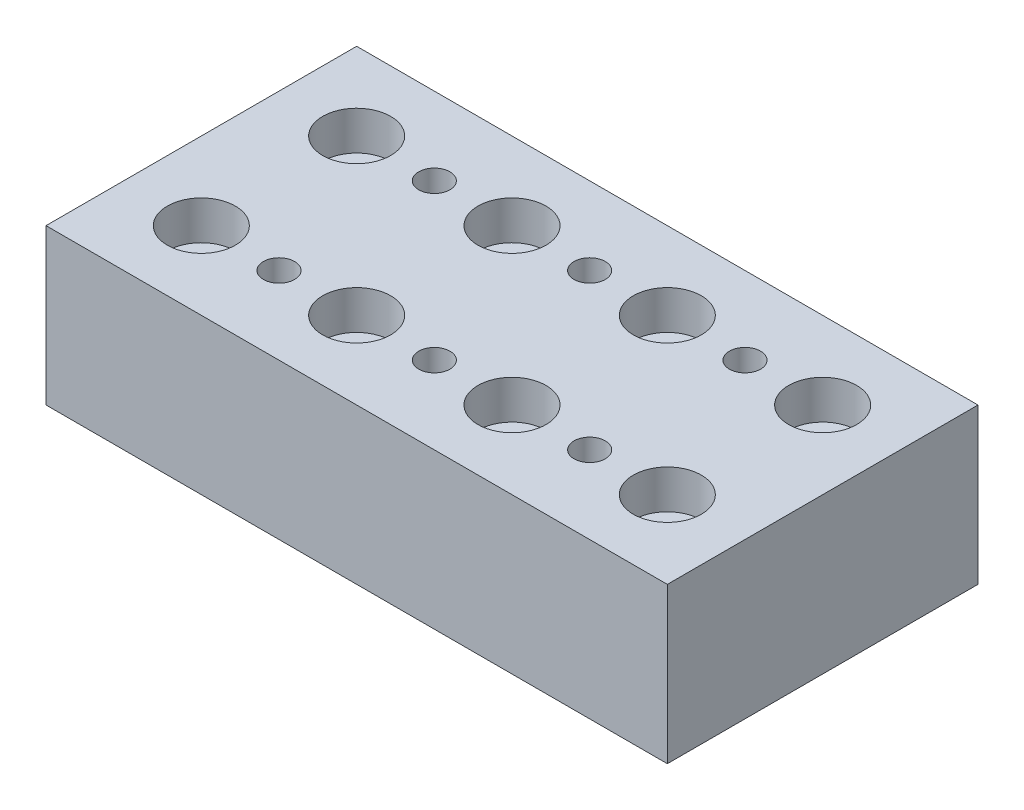
from build123d import *

# Parameters (mm, degrees)
SKETCH1_W                                        = 101.6
SKETCH1_H                                        = 50.8
BOSS_EXTRUDE1_DEPTH                              = 25.4
CBORE_FOR_1_4_SOCKET_HEAD_CAP_SCREW1_D           = 6.7564
CBORE_FOR_1_4_SOCKET_HEAD_CAP_SCREW1_CBORE_D     = 11.1125
CBORE_FOR_1_4_SOCKET_HEAD_CAP_SCREW1_CBORE_DEPTH = 6.35
LPATTERN1_COUNT                                  = 2
LPATTERN1_PITCH                                  = 25.4
LPATTERN1_COUNT_DIR2                             = 4
LPATTERN1_PITCH_DIR2                             = 25.4
F_1_4_20_TAPPED_HOLE1_D                          = 5.1054
LPATTERN2_COUNT                                  = 2
LPATTERN2_PITCH                                  = 25.4
LPATTERN2_COUNT_DIR2                             = 3
LPATTERN2_PITCH_DIR2                             = 25.4


with BuildPart() as part:
    # Sketch1 → Boss-Extrude1 (new body)
    with BuildSketch(Plane(origin=(0, 0, 0), x_dir=(1, 0, 0), z_dir=(0, 1, 0))):
        with Locations((50.8, 25.4)):
            Rectangle(SKETCH1_W, SKETCH1_H)
    extrude(amount=BOSS_EXTRUDE1_DEPTH)

    # CBORE for 1/4 Socket Head Cap Screw1 (through all)
    with Locations(Plane(origin=(0, 25.4, 0), x_dir=(-1, 0, 0), z_dir=(0, 1, 0))):
        with Locations((-12.7, -12.7)):
            cbore_for_1_4_socket_head_cap_screw1 = CounterBoreHole(CBORE_FOR_1_4_SOCKET_HEAD_CAP_SCREW1_D / 2, CBORE_FOR_1_4_SOCKET_HEAD_CAP_SCREW1_CBORE_D / 2, CBORE_FOR_1_4_SOCKET_HEAD_CAP_SCREW1_CBORE_DEPTH)

    # LPattern1: CBORE for 1_4 Socket Head Cap Screw1 2 × 4
    with Locations(*[(j * LPATTERN1_PITCH_DIR2, 0, -i * LPATTERN1_PITCH) for i in range(LPATTERN1_COUNT) for j in range(LPATTERN1_COUNT_DIR2) if (i, j) != (0, 0)]):
        add(cbore_for_1_4_socket_head_cap_screw1, mode=Mode.SUBTRACT)

    # 1/4-20 Tapped Hole1 (through all)
    with Locations(Plane(origin=(0, 25.4, 0), x_dir=(-1, 0, 0), z_dir=(0, 1, 0))):
        with Locations((-25.4, -38.1)):
            f_1_4_20_tapped_hole1 = Hole(F_1_4_20_TAPPED_HOLE1_D / 2)

    # LPattern2: 1_4-20 Tapped Hole1 2 × 3
    with Locations(*[(j * LPATTERN2_PITCH_DIR2, 0, i * LPATTERN2_PITCH) for i in range(LPATTERN2_COUNT) for j in range(LPATTERN2_COUNT_DIR2) if (i, j) != (0, 0)]):
        add(f_1_4_20_tapped_hole1, mode=Mode.SUBTRACT)


solid = part.part
